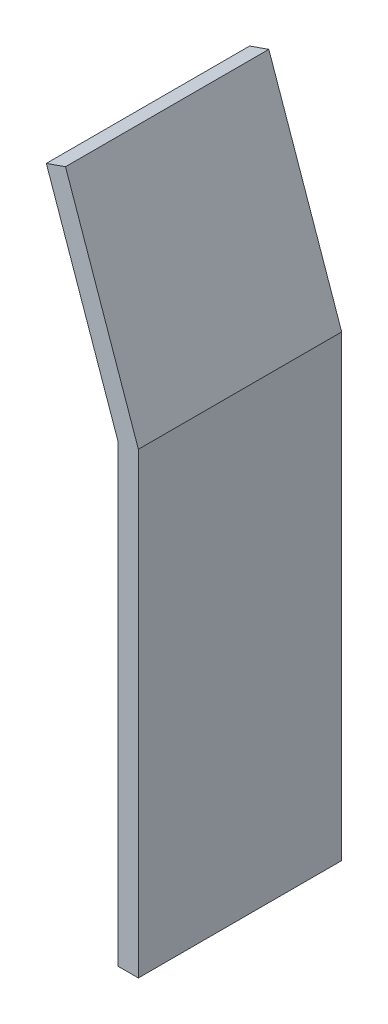
from build123d import *

# Parameters (mm, degrees)
BOSS_EXTRUDE1_DEPTH = 200


with BuildPart() as part:
    # Sketch1 → Boss-Extrude1 (new body)
    with BuildSketch(Plane.XY):
        Polygon((0, 0), (0, -447), (20, -447), (20, 3.397110563), (-51.668985533, 208.280847734), (-70.547310841, 201.677149259), align=None)
    extrude(amount=BOSS_EXTRUDE1_DEPTH)


solid = part.part
